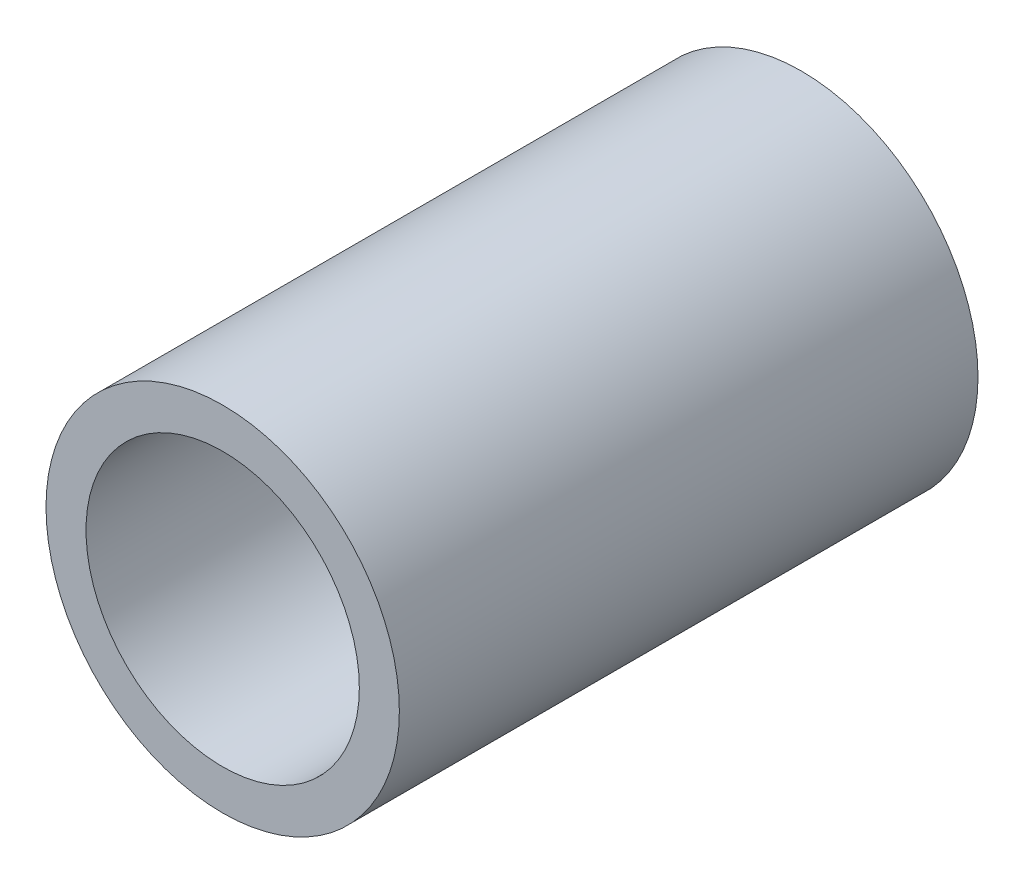
from build123d import *

# Parameters (mm, degrees)
ESQUISSE1_R             = 4.415
BOSS_EXTRU_1_DEPTH      = 14.46
ESQUISSE4_R             = 2.9
ENL_V_MAT_EXTRU_1_DEPTH = 14.46
ESQUISSE6_R             = 3.415
ENL_V_MAT_EXTRU_2_DEPTH = 7


with BuildPart() as part:
    # Esquisse1 → Boss.-Extru.1 (new body)
    with BuildSketch(Plane.XY):
        Circle(ESQUISSE1_R)
    extrude(amount=BOSS_EXTRU_1_DEPTH)

    # Esquisse4 → Enlèv. mat.-Extru.1 (cut)
    with BuildSketch(Plane.XY.offset(14.46)):
        Circle(ESQUISSE4_R)
    extrude(amount=-ENL_V_MAT_EXTRU_1_DEPTH, mode=Mode.SUBTRACT)

    # Esquisse6 → Enlèv. mat.-Extru.2 (cut)
    with BuildSketch(Plane.XY.offset(14.46)):
        Circle(ESQUISSE6_R)
    extrude(amount=-ENL_V_MAT_EXTRU_2_DEPTH, mode=Mode.SUBTRACT)


solid = part.part
